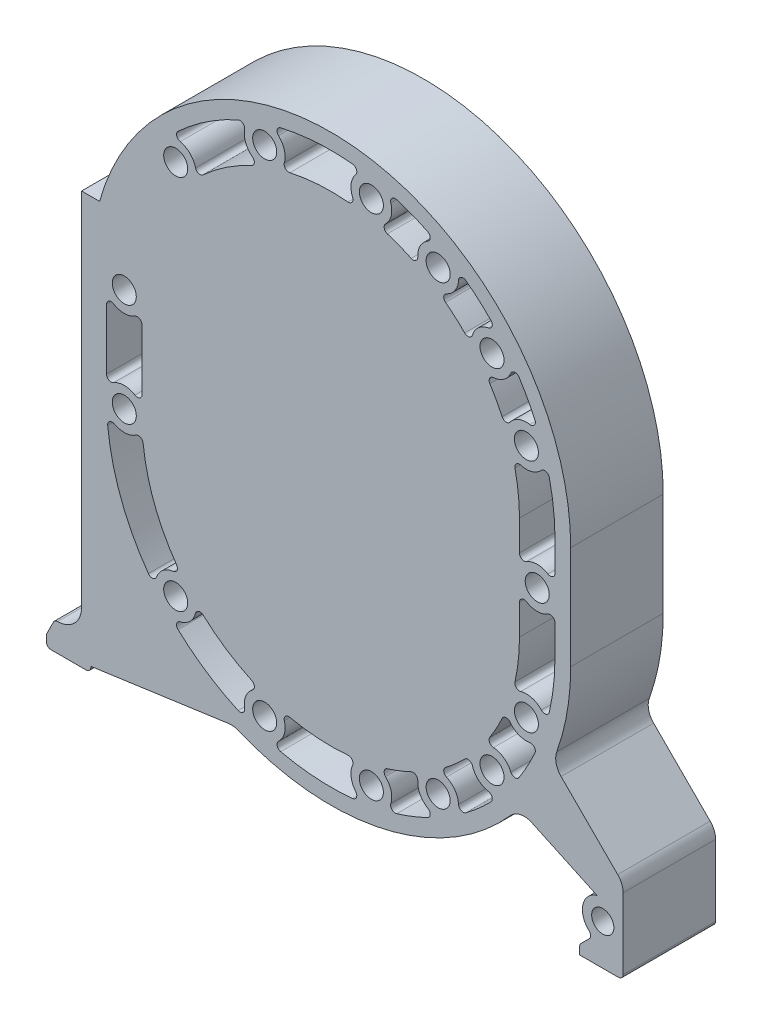
from build123d import *

# Parameters (mm, degrees)
CROQUIS1_R              = 6.5
CROQUIS1_R_2            = 6
SALIENTE_EXTRUIR1_DEPTH = 25


with BuildPart() as part:
    # Croquis1 → Saliente-Extruir1 (new body, symmetric)
    with BuildSketch(Plane.XY):
        with BuildLine():
            ThreePointArc((-134.69, -132.375), (-138.484242845, -141.553999684), (-147.652159261, -145.374944926))
            ThreePointArc((-147.652159261, -145.374944926), (-148.962303708, -145.750222458), (-149.880950173, -146.756900346))
            Line((-149.880950173, -146.756900346), (-153.426067977, -153.847135955))
            ThreePointArc((-153.426067977, -153.847135955), (-153.623122474, -154.390787642), (-153.69, -154.965169944))
            Line((-153.69, -154.965169944), (-153.69, -157.875))
            ThreePointArc((-153.69, -157.875), (-152.957766953, -159.642766953), (-151.19, -160.375))
            Line((-151.19, -160.375), (-132.19, -160.375))
            ThreePointArc((-132.19, -160.375), (-130.422233047, -159.642766953), (-129.69, -157.875))
            Line((-129.69, -157.875), (-129.69, -157.375))
            Line((-129.69, -157.375), (-55.158579324, -146.900291927))
            ThreePointArc((-55.158579324, -146.900291927), (-52.492947099, -146.884445723), (-49.917836337, -147.573394791))
            ThreePointArc((-49.917836337, -147.573394791), (28.987217755, -154.284008013), (97.084575956, -113.863843529))
            ThreePointArc((97.084575956, -113.863843529), (102.536758276, -110.703163877), (108.796653859, -111.431102888))
            Line((108.796653859, -111.431102888), (143.927407435, -127.812842317))
            ThreePointArc((143.927407435, -127.812842317), (136.279437091, -135.911358201), (139.624687231, -146.536174031))
            ThreePointArc((139.624687231, -146.536174031), (140.447681655, -148.3278198), (139.716246737, -150.158753263))
            Line((139.716246737, -150.158753263), (135.232233047, -154.642766953))
            ThreePointArc((135.232233047, -154.642766953), (134.690301169, -155.453825325), (134.5, -156.410533906))
            Line((134.5, -156.410533906), (134.5, -160.375))
            Line((134.5, -160.375), (155.5, -160.375))
            ThreePointArc((155.5, -160.375), (157.267766953, -159.642766953), (158, -157.875))
            Line((158, -157.875), (158, -119.517135624))
            ThreePointArc((158, -119.517135624), (157.238795325, -115.6903013), (155.071067812, -112.446067812))
            Line((155.071067812, -112.446067812), (124.500071536, -81.875071536))
            ThreePointArc((124.500071536, -81.875071536), (121.81521137, -76.99987924), (122.152344922, -71.444493114))
            ThreePointArc((122.152344922, -71.444493114), (127.791693222, -49.983352348), (129.69, -27.875))
            Line((129.69, -27.875), (129.69, 27.875))
            ThreePointArc((129.69, 27.875), (17.536046352, 156.373961779), (-124.947723469, 62.625))
            Line((-124.947723469, 62.625), (-134.69, 62.625))
            Line((-134.69, 62.625), (-134.69, -132.375))
        make_face()
        with BuildLine():
            ThreePointArc((96.881838077, 70.181637167), (94.617844513, 69.189341257), (92.607693174, 70.627955044))
            ThreePointArc((92.607693174, 70.627955044), (89.502289234, 76.796776562), (85.986555557, 82.741312647))
            ThreePointArc((85.986555557, 82.741312647), (85.860969449, 85.21002611), (87.918575263, 86.579907982))
            ThreePointArc((87.918575263, 86.579907982), (93.58164813, 88.624225414), (97.329935976, 93.335909432))
            ThreePointArc((97.329935976, 93.335909432), (99.413600426, 94.862000368), (101.735299255, 93.730485615))
            ThreePointArc((101.735299255, 93.730485615), (106.341004237, 86.000785309), (110.360514506, 77.950672117))
            ThreePointArc((110.360514506, 77.950672117), (110.059399709, 75.385532556), (107.649852788, 74.455642928))
            ThreePointArc((107.649852788, 74.455642928), (101.660176363, 73.844574687), (96.881838077, 70.181637167))
        make_face(mode=Mode.SUBTRACT)
        with Locations((87.143594155, 97.592673497)):
            Circle(CROQUIS1_R, mode=Mode.SUBTRACT)
        with Locations((-83.790831702, -101.588340195)):
            Circle(CROQUIS1_R, mode=Mode.SUBTRACT)
        with Locations((-35.708318761, -133.608041058)):
            Circle(CROQUIS1_R, mode=Mode.SUBTRACT)
        with BuildLine():
            ThreePointArc((11.813453088, -148.487845195), (-7.73820149, -148.817698571), (-27.088392238, -145.998812612))
            ThreePointArc((-27.088392238, -145.998812612), (-28.945736068, -144.204130193), (-28.224334891, -141.724172244))
            ThreePointArc((-28.224334891, -141.724172244), (-25.078790134, -136.590442972), (-25.094645122, -130.569697447))
            ThreePointArc((-25.094645122, -130.569697447), (-24.511119871, -128.167653252), (-22.148335068, -127.441315859))
            ThreePointArc((-22.148335068, -127.441315859), (-6.512885156, -129.666857862), (9.278701432, -129.452092397))
            ThreePointArc((9.278701432, -129.452092397), (11.529653187, -130.473627628), (11.802296503, -132.930451523))
            ThreePointArc((11.802296503, -132.930451523), (11.019268702, -138.900082628), (13.484906294, -144.392828692))
            ThreePointArc((13.484906294, -144.392828692), (13.884371714, -146.944502351), (11.813453088, -148.487845195))
        make_face(mode=Mode.SUBTRACT)
        with BuildLine():
            ThreePointArc((-50.075672117, -138.235514506), (-67.172828356, -128.74534862), (-82.521142132, -116.629026395))
            ThreePointArc((-82.521142132, -116.629026395), (-83.232307863, -114.146113913), (-81.367577143, -112.359107918))
            ThreePointArc((-81.367577143, -112.359107918), (-76.076590838, -109.48594033), (-73.079948898, -104.263894262))
            ThreePointArc((-73.079948898, -104.263894262), (-71.373579109, -102.475425594), (-68.96417875, -103.027791361))
            ThreePointArc((-68.96417875, -103.027791361), (-56.536252928, -112.772892229), (-42.752955044, -120.482693174))
            ThreePointArc((-42.752955044, -120.482693174), (-41.314341257, -122.492844513), (-42.306637167, -124.756838077))
            ThreePointArc((-42.306637167, -124.756838077), (-45.969574687, -129.535176363), (-46.580642928, -135.524852787))
            ThreePointArc((-46.580642928, -135.524852787), (-47.510532556, -137.934399709), (-50.075672117, -138.235514506))
        make_face(mode=Mode.SUBTRACT)
        with BuildLine():
            ThreePointArc((-98.547061418, -98.412173079), (-113.38922347, -70.652331624), (-120.581280229, -40.006403811))
            ThreePointArc((-120.581280229, -40.006403811), (-119.475235387, -37.672463817), (-116.894827512, -37.562435244))
            ThreePointArc((-116.894827512, -37.562435244), (-111.024514584, -38.899990546), (-105.325360652, -36.958529108))
            ThreePointArc((-105.325360652, -36.958529108), (-102.862886251, -36.74280276), (-101.418720173, -38.748968848))
            ThreePointArc((-101.418720173, -38.748968848), (-95.434448337, -63.878695236), (-83.328991742, -86.699137353))
            ThreePointArc((-83.328991742, -86.699137353), (-83.088191325, -89.159286371), (-85.079541574, -90.623814356))
            ThreePointArc((-85.079541574, -90.623814356), (-90.640907662, -92.93050794), (-94.164946494, -97.812185764))
            ThreePointArc((-94.164946494, -97.812185764), (-96.175027995, -99.433969795), (-98.547061418, -98.412173079))
        make_face(mode=Mode.SUBTRACT)
        with Locations((-111.6, -27.875)):
            Circle(CROQUIS1_R, mode=Mode.SUBTRACT)
        with Locations((21.942209355, -137.296658956)):
            Circle(CROQUIS1_R, mode=Mode.SUBTRACT)
        with BuildLine():
            ThreePointArc((52.353037294, -137.173561684), (44.099400772, -140.756614763), (35.60267048, -143.717418633))
            ThreePointArc((35.60267048, -143.717418633), (33.09682233, -143.091849982), (32.481595101, -140.583442809))
            ThreePointArc((32.481595101, -140.583442809), (32.638852133, -134.564730464), (29.614748548, -129.358539384))
            ThreePointArc((29.614748548, -129.358539384), (28.919074143, -126.986545465), (30.602137109, -125.176126429))
            ThreePointArc((30.602137109, -125.176126429), (37.116419496, -122.88221764), (43.460538967, -120.152741372))
            ThreePointArc((43.460538967, -120.152741372), (45.925127347, -120.342799649), (47.021611519, -122.558209428))
            ThreePointArc((47.021611519, -122.558209428), (48.327540158, -128.435639007), (52.523111405, -132.753834228))
            ThreePointArc((52.523111405, -132.753834228), (53.771209903, -135.014997917), (52.353037294, -137.173561684))
        make_face(mode=Mode.SUBTRACT)
        with Locations((58.043343694, -123.193047886)):
            Circle(CROQUIS1_R, mode=Mode.SUBTRACT)
        with BuildLine():
            ThreePointArc((86.578072553, -112.676258558), (80.047667547, -118.866137043), (73.076007354, -124.554435503))
            ThreePointArc((73.076007354, -124.554435503), (70.50732326, -124.823643801), (69.071272992, -122.676932196))
            ThreePointArc((69.071272992, -122.676932196), (67.160525406, -116.967407546), (62.538175363, -113.109492547))
            ThreePointArc((62.538175363, -113.109492547), (61.073185557, -111.118482025), (62.035547628, -108.84160318))
            ThreePointArc((62.035547628, -108.84160318), (67.372407705, -104.458018222), (72.400394092, -99.723332864))
            ThreePointArc((72.400394092, -99.723332864), (74.781353365, -99.058990353), (76.569426221, -100.765774901))
            ThreePointArc((76.569426221, -100.765774901), (79.806797033, -105.842098204), (85.226254123, -108.46490451))
            ThreePointArc((85.226254123, -108.46490451), (87.1724466, -110.162828515), (86.578072553, -112.676258558))
        make_face(mode=Mode.SUBTRACT)
        with Locations((147, -138.375)):
            Circle(CROQUIS1_R_2, mode=Mode.SUBTRACT)
        with Locations((87.143594155, -97.592673497)):
            Circle(CROQUIS1_R, mode=Mode.SUBTRACT)
        with BuildLine():
            ThreePointArc((110.360514506, -77.950672117), (106.341004237, -86.000785309), (101.735299255, -93.730485615))
            ThreePointArc((101.735299255, -93.730485615), (99.413600426, -94.862000368), (97.329935976, -93.335909432))
            ThreePointArc((97.329935976, -93.335909432), (93.58164813, -88.624225414), (87.918575263, -86.579907982))
            ThreePointArc((87.918575263, -86.579907982), (85.860969449, -85.21002611), (85.986555557, -82.741312647))
            ThreePointArc((85.986555557, -82.741312647), (89.502289234, -76.796776562), (92.607693174, -70.627955044))
            ThreePointArc((92.607693174, -70.627955044), (94.617844513, -69.189341257), (96.881838077, -70.181637167))
            ThreePointArc((96.881838077, -70.181637167), (101.660176363, -73.844574687), (107.649852788, -74.455642928))
            ThreePointArc((107.649852788, -74.455642928), (110.059399709, -75.385532556), (110.360514506, -77.950672117))
        make_face(mode=Mode.SUBTRACT)
        with Locations((105.733041058, -63.583318761)):
            Circle(CROQUIS1_R, mode=Mode.SUBTRACT)
        with BuildLine():
            Line((102, -27.875), (102, -11.529163023))
            ThreePointArc((102, -11.529163023), (103.280845875, -9.346581244), (105.810930576, -9.40044016))
            ThreePointArc((105.810930576, -9.40044016), (111.595213419, -11.039998962), (117.380915805, -9.405456526))
            ThreePointArc((117.380915805, -9.405456526), (119.910100306, -9.353262352), (121.19, -11.53531534))
            Line((121.19, -11.53531534), (121.19, -27.875))
            ThreePointArc((121.19, -27.875), (120.421013429, -41.505686879), (118.123812612, -54.963392238))
            ThreePointArc((118.123812612, -54.963392238), (116.329130193, -56.820736068), (113.849172244, -56.099334891))
            ThreePointArc((113.849172244, -56.099334891), (108.715442972, -52.953790134), (102.694697447, -52.969645122))
            ThreePointArc((102.694697447, -52.969645122), (100.292653252, -52.386119871), (99.566315859, -50.023335068))
            ThreePointArc((99.566315859, -50.023335068), (101.38975347, -39.015820939), (102, -27.875))
        make_face(mode=Mode.SUBTRACT)
        with BuildLine():
            Line((-102, 16.345836977), (-102, -16.345836977))
            ThreePointArc((-102, -16.345836977), (-103.280845875, -18.528418756), (-105.810930576, -18.47455984))
            ThreePointArc((-105.810930576, -18.47455984), (-111.595213419, -16.835001038), (-117.380915805, -18.469543474))
            ThreePointArc((-117.380915805, -18.469543474), (-119.910100306, -18.521737648), (-121.19, -16.33968466))
            Line((-121.19, -16.33968466), (-121.19, 16.33968466))
            ThreePointArc((-121.19, 16.33968466), (-119.910100306, 18.521737648), (-117.380915805, 18.469543474))
            ThreePointArc((-117.380915805, 18.469543474), (-111.595213419, 16.835001038), (-105.810930576, 18.47455984))
            ThreePointArc((-105.810930576, 18.47455984), (-103.280845875, 18.528418756), (-102, 16.345836977))
        make_face(mode=Mode.SUBTRACT)
        with Locations((-111.6, 27.875)):
            Circle(CROQUIS1_R, mode=Mode.SUBTRACT)
        with Locations((-83.790831702, 101.588340195)):
            Circle(CROQUIS1_R, mode=Mode.SUBTRACT)
        with BuildLine():
            ThreePointArc((-50.075672117, 138.235514506), (-47.510532556, 137.934399709), (-46.580642928, 135.524852787))
            ThreePointArc((-46.580642928, 135.524852787), (-45.969574687, 129.535176363), (-42.306637167, 124.756838077))
            ThreePointArc((-42.306637167, 124.756838077), (-41.314341257, 122.492844513), (-42.752955044, 120.482693174))
            ThreePointArc((-42.752955044, 120.482693174), (-56.536252928, 112.772892229), (-68.96417875, 103.027791361))
            ThreePointArc((-68.96417875, 103.027791361), (-71.373579109, 102.475425594), (-73.079948898, 104.263894262))
            ThreePointArc((-73.079948898, 104.263894262), (-76.076590838, 109.48594033), (-81.367577143, 112.359107918))
            ThreePointArc((-81.367577143, 112.359107918), (-83.232307863, 114.146113913), (-82.521142132, 116.629026395))
            ThreePointArc((-82.521142132, 116.629026395), (-67.172828356, 128.74534862), (-50.075672117, 138.235514506))
        make_face(mode=Mode.SUBTRACT)
        with Locations((-35.708318761, 133.608041058)):
            Circle(CROQUIS1_R, mode=Mode.SUBTRACT)
        with BuildLine():
            ThreePointArc((11.813453088, 148.487845195), (13.884371714, 146.944502351), (13.484906294, 144.392828692))
            ThreePointArc((13.484906294, 144.392828692), (11.019268702, 138.900082628), (11.802296503, 132.930451523))
            ThreePointArc((11.802296503, 132.930451523), (11.529653187, 130.473627628), (9.278701432, 129.452092397))
            ThreePointArc((9.278701432, 129.452092397), (-6.512885156, 129.666857862), (-22.148335068, 127.441315859))
            ThreePointArc((-22.148335068, 127.441315859), (-24.511119871, 128.167653252), (-25.094645122, 130.569697447))
            ThreePointArc((-25.094645122, 130.569697447), (-25.078790134, 136.590442972), (-28.224334891, 141.724172244))
            ThreePointArc((-28.224334891, 141.724172244), (-28.945736068, 144.204130193), (-27.088392238, 145.998812612))
            ThreePointArc((-27.088392238, 145.998812612), (-7.73820149, 148.817698571), (11.813453088, 148.487845195))
        make_face(mode=Mode.SUBTRACT)
        with Locations((111.6, 0)):
            Circle(CROQUIS1_R, mode=Mode.SUBTRACT)
        with BuildLine():
            Line((121.19, 27.875), (121.19, 11.53531534))
            ThreePointArc((121.19, 11.53531534), (119.910100306, 9.353262352), (117.380915805, 9.405456526))
            ThreePointArc((117.380915805, 9.405456526), (111.595213419, 11.039998962), (105.810930576, 9.40044016))
            ThreePointArc((105.810930576, 9.40044016), (103.280845875, 9.346581244), (102, 11.529163023))
            Line((102, 11.529163023), (102, 27.875))
            ThreePointArc((102, 27.875), (101.38975347, 39.015820939), (99.566315859, 50.023335068))
            ThreePointArc((99.566315859, 50.023335068), (100.292653252, 52.386119871), (102.694697447, 52.969645122))
            ThreePointArc((102.694697447, 52.969645122), (108.715442972, 52.953790134), (113.849172244, 56.099334891))
            ThreePointArc((113.849172244, 56.099334891), (116.329130193, 56.820736068), (118.123812612, 54.963392238))
            ThreePointArc((118.123812612, 54.963392238), (120.421013429, 41.505686879), (121.19, 27.875))
        make_face(mode=Mode.SUBTRACT)
        with Locations((105.733041058, 63.583318761)):
            Circle(CROQUIS1_R, mode=Mode.SUBTRACT)
        with BuildLine():
            ThreePointArc((73.076007354, 124.554435503), (80.047667547, 118.866137043), (86.578072553, 112.676258558))
            ThreePointArc((86.578072553, 112.676258558), (87.1724466, 110.162828515), (85.226254123, 108.46490451))
            ThreePointArc((85.226254123, 108.46490451), (79.806797033, 105.842098204), (76.569426221, 100.765774901))
            ThreePointArc((76.569426221, 100.765774901), (74.781353365, 99.058990353), (72.400394092, 99.723332864))
            ThreePointArc((72.400394092, 99.723332864), (67.372407705, 104.458018222), (62.035547628, 108.84160318))
            ThreePointArc((62.035547628, 108.84160318), (61.073185557, 111.118482025), (62.538175363, 113.109492547))
            ThreePointArc((62.538175363, 113.109492547), (67.160525406, 116.967407546), (69.071272992, 122.676932196))
            ThreePointArc((69.071272992, 122.676932196), (70.50732326, 124.823643801), (73.076007354, 124.554435503))
        make_face(mode=Mode.SUBTRACT)
        with Locations((21.942209355, 137.296658956)):
            Circle(CROQUIS1_R, mode=Mode.SUBTRACT)
        with Locations((58.043343694, 123.193047886)):
            Circle(CROQUIS1_R, mode=Mode.SUBTRACT)
        with BuildLine():
            ThreePointArc((35.60267048, 143.717418633), (44.099400772, 140.756614763), (52.353037294, 137.173561684))
            ThreePointArc((52.353037294, 137.173561684), (53.771209903, 135.014997917), (52.523111405, 132.753834228))
            ThreePointArc((52.523111405, 132.753834228), (48.327540158, 128.435639007), (47.021611519, 122.558209428))
            ThreePointArc((47.021611519, 122.558209428), (45.925127347, 120.342799649), (43.460538967, 120.152741372))
            ThreePointArc((43.460538967, 120.152741372), (37.116419496, 122.88221764), (30.602137109, 125.176126429))
            ThreePointArc((30.602137109, 125.176126429), (28.919074143, 126.986545465), (29.614748548, 129.358539384))
            ThreePointArc((29.614748548, 129.358539384), (32.638852133, 134.564730464), (32.481595101, 140.583442809))
            ThreePointArc((32.481595101, 140.583442809), (33.09682233, 143.091849982), (35.60267048, 143.717418633))
        make_face(mode=Mode.SUBTRACT)
    extrude(amount=SALIENTE_EXTRUIR1_DEPTH, both=True)


solid = part.part
